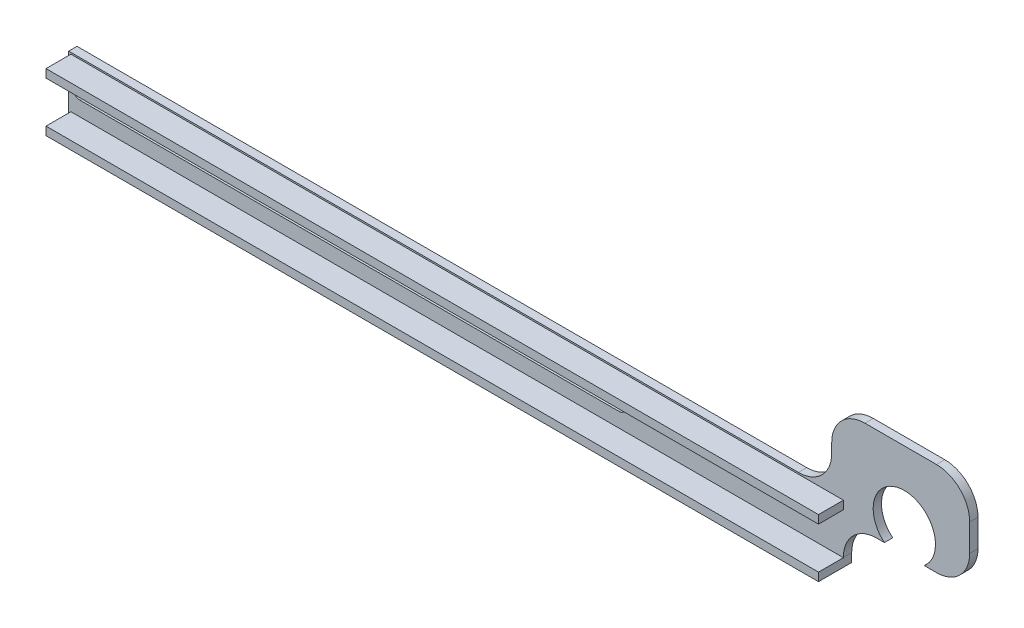
from build123d import *

# Parameters (mm, degrees)
BOSS_EXTRUDE1_DEPTH = 2.54
SKETCH2_R           = 9.525
CUT_EXTRUDE1_DEPTH  = 19.05
SKETCH3_W           = 236.278650797
SKETCH3_H           = 2.54
BOSS_EXTRUDE2_DEPTH = 7.62
CUT_EXTRUDE2_DEPTH  = 3.54
FILLET1_R           = 10.16


with BuildPart() as part:
    # Sketch1 → Boss-Extrude1 (new body)
    with BuildSketch(Plane.XY.offset(-12.457776114)):
        Polygon((-279.4, 85.357628122), (127, 85.357628122), (127, 21.857628122), (0, 21.857628122), (0, -12.141055663), (-279.4, -12.141055663), align=None)
        with BuildLine():
            Line((-233.58, 19.833203878), (-68.58, 19.833203878))
            ThreePointArc((-68.58, 19.833203878), (-66.675, 17.928203878), (-68.58, 16.023203878))
            Line((-68.58, 16.023203878), (-233.58, 16.023203878))
            ThreePointArc((-233.58, 16.023203878), (-235.485, 17.928203878), (-233.58, 19.833203878))
        make_face(mode=Mode.SUBTRACT)
    extrude(amount=-BOSS_EXTRUDE1_DEPTH)

    # Sketch2 → Cut-Extrude1 (cut)
    with BuildSketch(Plane.XY.offset(-12.457776114)):
        with Locations((18.627536258, 29.178203878)):
            Circle(SKETCH2_R)
    extrude(amount=-CUT_EXTRUDE1_DEPTH, mode=Mode.SUBTRACT)

    # Sketch3 → Boss-Extrude2 (add)
    with BuildSketch(Plane.XY.offset(-12.457776114)):
        with Locations((-118.139325399, 25.548203878)):
            Rectangle(SKETCH3_W, SKETCH3_H)
        with Locations((-118.139325399, 10.308203878)):
            Rectangle(SKETCH3_W, SKETCH3_H)
    extrude(amount=BOSS_EXTRUDE2_DEPTH)

    # Sketch4 → Cut-Extrude2 (cut, through all)
    with BuildSketch(Plane.XY.offset(-12.457776114)):
        Polygon((-279.4, -12.141055663), (0, -12.141055663), (0, 9.038203878), (-236.955667324, 9.038203878), (-236.955667324, 27.294063936), (-3.574037437, 27.294063936), (-3.574037437, 50.510436651), (38.627466089, 50.510436651), (38.627466089, 2.859516917), (133.335307594, 2.859516917), (133.335307594, 92.146273099), (38.627466089, 92.146273099), (38.627466089, 93.769303319), (-279.4, 93.769303319), align=None)
    extrude(amount=-CUT_EXTRUDE2_DEPTH, mode=Mode.SUBTRACT)

    # Fillet1
    fillet1_edges = [part.edges().sort_by_distance(p)[0] for p in [
        (0, 21.857628122, -13.727776114),
        (-3.574037437, 27.294063936, -13.727776114),
        (38.627466089, 21.857628122, -13.727776114),
        (-3.574037437, 50.510436651, -13.727776114),
        (38.627466089, 50.510436651, -13.727776114),
    ]]
    fillet(fillet1_edges, radius=FILLET1_R)


solid = part.part
